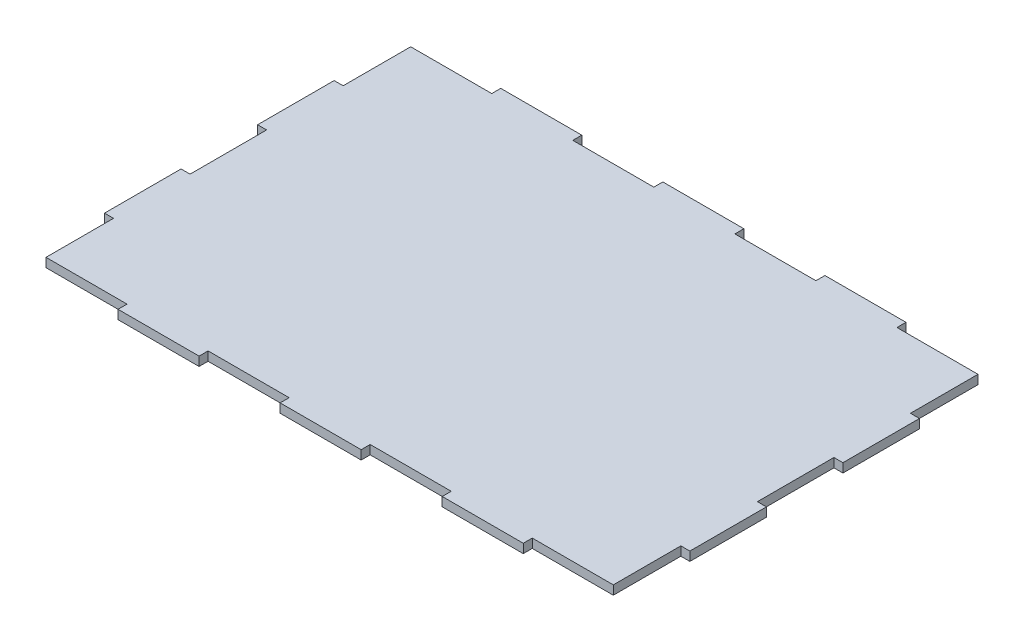
from build123d import *

# Parameters (mm, degrees)
SKETCH1_W           = 10.16
SKETCH1_H           = 86.36
SKETCH1_W_2         = 91.44
SKETCH1_H_2         = 10.16
BOSS_EXTRUDE1_DEPTH = 10.16


with BuildPart() as part:
    # Sketch1 → Boss-Extrude1 (new body)
    with BuildSketch(Plane(origin=(0, 0, 0), x_dir=(1, 0, 0), z_dir=(0, 1, 0))):
        Polygon((-228.6, 205.74), (-137.16, 205.74), (-45.72, 205.74), (45.72, 205.74), (137.16, 205.74), (228.6, 205.74), (320.04, 205.74), (320.04, 129.54), (320.04, 43.18), (320.04, -43.18), (320.04, -129.54), (320.04, -205.74), (228.6, -205.74), (137.16, -205.74), (45.72, -205.74), (-45.72, -205.74), (-137.16, -205.74), (-228.6, -205.74), (-320.04, -205.74), (-320.04, -129.54), (-320.04, -43.18), (-320.04, 43.18), (-320.04, 129.54), (-320.04, 205.74), align=None)
        with Locations((-325.12, 86.36)):
            Rectangle(SKETCH1_W, SKETCH1_H)
        with Locations((-325.12, -86.36)):
            Rectangle(SKETCH1_W, SKETCH1_H)
        with Locations((-182.88, -210.82)):
            Rectangle(SKETCH1_W_2, SKETCH1_H_2)
        with Locations((0, -210.82)):
            Rectangle(SKETCH1_W_2, SKETCH1_H_2)
        with Locations((182.88, -210.82)):
            Rectangle(SKETCH1_W_2, SKETCH1_H_2)
        with Locations((325.12, -86.36)):
            Rectangle(SKETCH1_W, SKETCH1_H)
        with Locations((325.12, 86.36)):
            Rectangle(SKETCH1_W, SKETCH1_H)
        with Locations((-182.88, 210.82)):
            Rectangle(SKETCH1_W_2, SKETCH1_H_2)
        with Locations((0, 210.82)):
            Rectangle(SKETCH1_W_2, SKETCH1_H_2)
        with Locations((182.88, 210.82)):
            Rectangle(SKETCH1_W_2, SKETCH1_H_2)
    extrude(amount=BOSS_EXTRUDE1_DEPTH)


solid = part.part
